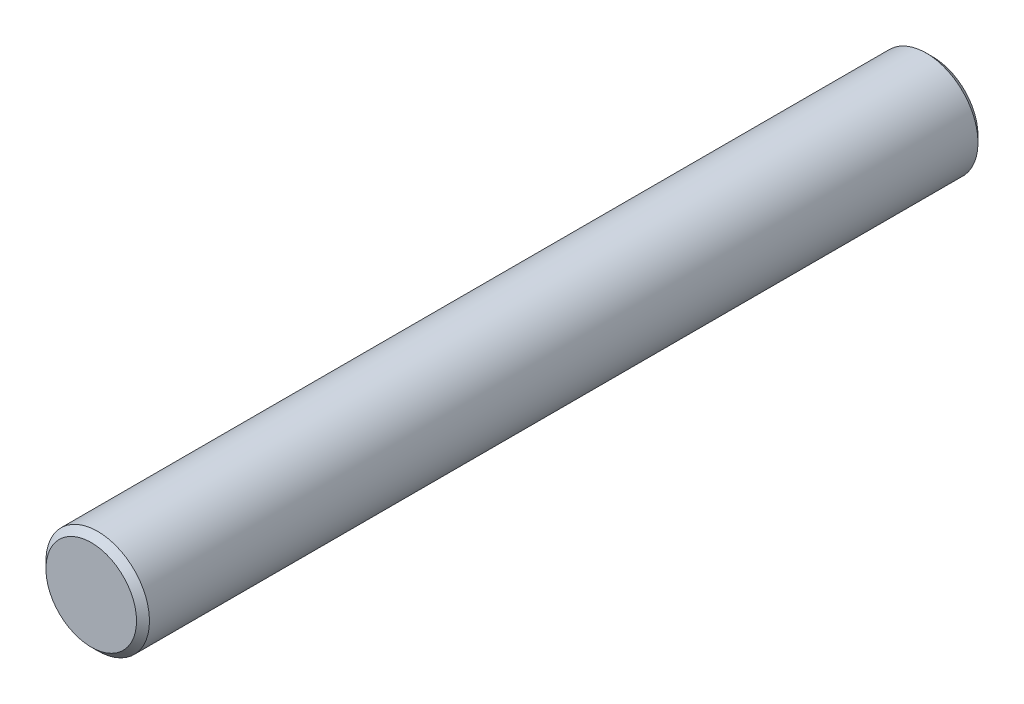
from build123d import *

# Parameters (mm, degrees)
ESQUISSE1_R        = 4
BOSS_EXTRU_1_DEPTH = 65
CHANFREIN1_SIZE    = 0.5


with BuildPart() as part:
    # Esquisse1 → Boss.-Extru.1 (new body)
    with BuildSketch(Plane.XY):
        Circle(ESQUISSE1_R)
    extrude(amount=BOSS_EXTRU_1_DEPTH)

    # Chanfrein1
    chanfrein1_edges = [part.edges().sort_by_distance(p)[0] for p in [
        (-4, 0, 0),
        (-4, 0, 65),
    ]]
    chamfer(chanfrein1_edges, length=CHANFREIN1_SIZE)


solid = part.part
